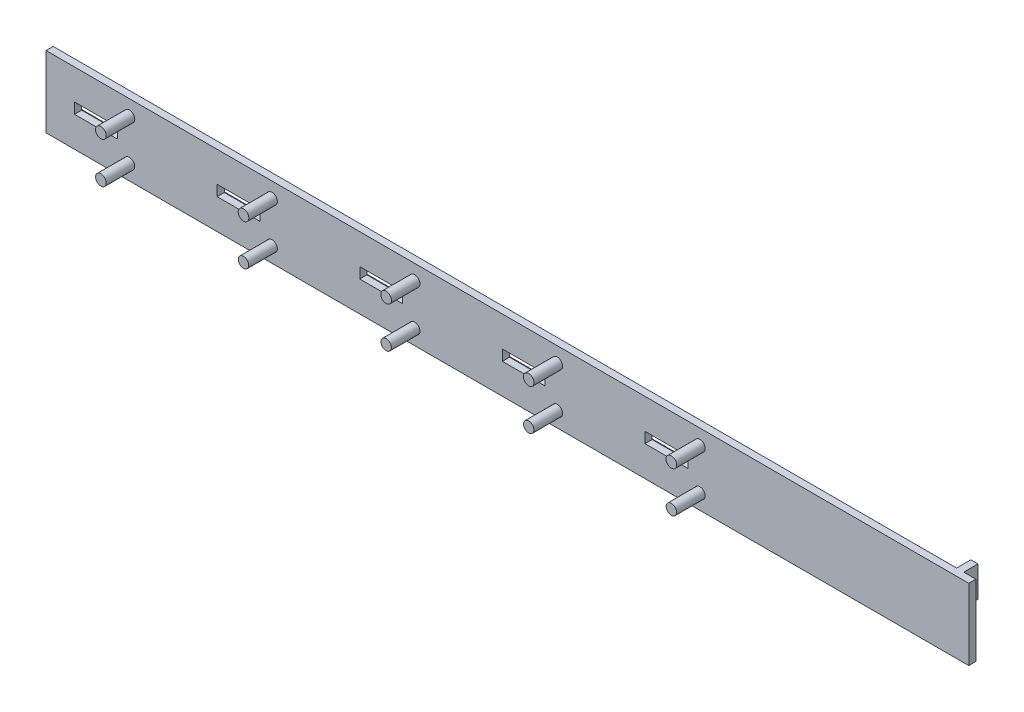
from build123d import *

# Parameters (mm, degrees)
SKETCH1_R               = 7.5
SKETCH1_W               = 60
SKETCH1_H               = 15
BOSS_EXTRUDE1_DEPTH     = 10
SKETCH3_R               = 7.5
SKETCH3_R_2             = 7.302638812
BOSS_EXTRUDE3_DEPTH     = 50
SKETCH6_W               = 900
SKETCH6_H               = 4
BOSS_EXTRUDE6_DEPTH     = 5
SKETCH7_W               = 10
SKETCH7_H               = 43
SKETCH7_H_2             = 45
BOSS_EXTRUDE7_DEPTH     = 20
CUT_EXTRUDE1_DEPTH      = 34.369507749
CUT_EXTRUDE1_DEPTH_BACK = 20


with BuildPart() as part:
    # Sketch1 → Boss-Extrude1 (new body)
    with BuildSketch(Plane.XY):
        Polygon((0, 0), (1000, 0), (1294.047453025, 0), (1294.047453025, 100), (1000, 100), (0, 100), align=None)
        with Locations((116.960149429, 78.75)):
            Circle(SKETCH1_R, mode=Mode.SUBTRACT)
        with Locations((116.960149429, 21.25)):
            Circle(SKETCH1_R, mode=Mode.SUBTRACT)
        with Locations((316.960149429, 78.75)):
            Circle(SKETCH1_R, mode=Mode.SUBTRACT)
        with Locations((316.960149429, 21.25)):
            Circle(SKETCH1_R, mode=Mode.SUBTRACT)
        with Locations((516.960149429, 78.75)):
            Circle(SKETCH1_R, mode=Mode.SUBTRACT)
        with Locations((516.960149429, 21.25)):
            Circle(SKETCH1_R, mode=Mode.SUBTRACT)
        with Locations((716.960149429, 78.75)):
            Circle(SKETCH1_R, mode=Mode.SUBTRACT)
        with Locations((716.960149429, 21.25)):
            Circle(SKETCH1_R, mode=Mode.SUBTRACT)
        with Locations((916.960149429, 78.75)):
            Circle(SKETCH1_R, mode=Mode.SUBTRACT)
        with Locations((916.960149429, 21.25)):
            Circle(SKETCH1_R, mode=Mode.SUBTRACT)
        with Locations((70, 50)):
            Rectangle(SKETCH1_W, SKETCH1_H, mode=Mode.SUBTRACT)
        with Locations((270, 50)):
            Rectangle(SKETCH1_W, SKETCH1_H, mode=Mode.SUBTRACT)
        with Locations((470, 50)):
            Rectangle(SKETCH1_W, SKETCH1_H, mode=Mode.SUBTRACT)
        with Locations((670, 50)):
            Rectangle(SKETCH1_W, SKETCH1_H, mode=Mode.SUBTRACT)
        with Locations((870, 50)):
            Rectangle(SKETCH1_W, SKETCH1_H, mode=Mode.SUBTRACT)
    extrude(amount=BOSS_EXTRUDE1_DEPTH)

    # Sketch3 → Boss-Extrude3 (add)
    with BuildSketch(Plane.XY):
        with Locations((116.960149429, 78.75)):
            Circle(SKETCH3_R)
        with Locations((116.960149429, 21.25)):
            Circle(SKETCH3_R)
        with Locations((316.960149429, 78.75)):
            Circle(SKETCH3_R)
        with Locations((316.960149429, 21.25)):
            Circle(SKETCH3_R_2)
        with Locations((516.960149429, 21.25)):
            Circle(SKETCH3_R_2)
        with Locations((516.960149429, 78.75)):
            Circle(SKETCH3_R)
        with Locations((716.960149429, 21.25)):
            Circle(SKETCH3_R_2)
        with Locations((716.960149429, 78.75)):
            Circle(SKETCH3_R)
        with Locations((916.960149429, 21.25)):
            Circle(SKETCH3_R_2)
        with Locations((916.960149429, 78.75)):
            Circle(SKETCH3_R)
    extrude(amount=BOSS_EXTRUDE3_DEPTH)

    # Sketch6 → Boss-Extrude6 (add)
    with BuildSketch(Plane(origin=(0, 0, 0), x_dir=(-1, 0, 0), z_dir=(0, 0, -1))):
        with Locations((-450, 63.5)):
            Rectangle(SKETCH6_W, SKETCH6_H)
        with Locations((-450, 36.5)):
            Rectangle(SKETCH6_W, SKETCH6_H)
    extrude(amount=BOSS_EXTRUDE6_DEPTH)

    # Sketch7 → Boss-Extrude7 (add)
    with BuildSketch(Plane.XY):
        with Locations((1271.986804567, 78.5)):
            Rectangle(SKETCH7_W, SKETCH7_H)
        with Locations((1255.677945276, 22.5)):
            Rectangle(SKETCH7_W, SKETCH7_H_2)
    extrude(amount=-BOSS_EXTRUDE7_DEPTH)

    # Sketch9 → Cut-Extrude1 (cut, two sides)
    with BuildSketch(Plane(origin=(1260.677945276, 0, 0), x_dir=(0, 0, -1), z_dir=(1, 0, 0))) as cut_extrude1_sk:
        with BuildLine():
            Line((20, 45), (0, 45))
            ThreePointArc((0, 45), (10, 38.510424835), (20, 45))
        make_face()
    extrude(amount=CUT_EXTRUDE1_DEPTH, mode=Mode.SUBTRACT)
    extrude(cut_extrude1_sk.sketch, amount=-CUT_EXTRUDE1_DEPTH_BACK, mode=Mode.SUBTRACT)


solid = part.part
